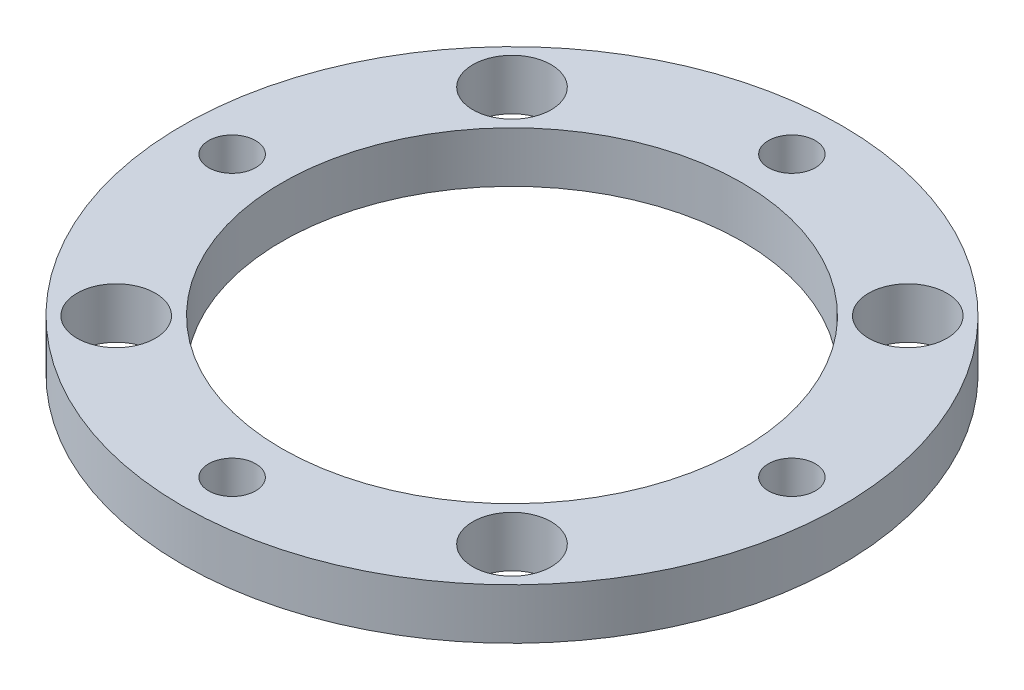
from build123d import *

# Parameters (mm, degrees)
PROFILE_SKETCH_R              = 20.6375
PROFILE_EXTRUDE_DEPTH         = 3.175
BORE_SKETCH_R                 = 14.4145
BORE_CUT_DEPTH                = 4.175
BOLT_CLEARANCE_SKETCH_R       = 1.4732
BOLT_CLEARANCE_CUT_DEPTH      = 4.175
BOLT_HEAD_CLEARANCE_SKETCH_R  = 2.4511
BOLT_HEAD_CLEARANCE_CUT_DEPTH = 4.175


with BuildPart() as part:
    # Profile Sketch → Profile Extrude (new body)
    with BuildSketch(Plane(origin=(0, 0, 0), x_dir=(1, 0, 0), z_dir=(0, 1, 0))):
        Circle(PROFILE_SKETCH_R)
    extrude(amount=PROFILE_EXTRUDE_DEPTH)

    # Bore Sketch → Bore Cut (cut, through all)
    with BuildSketch(Plane(origin=(0, 0, 0), x_dir=(-1, 0, 0), z_dir=(0, -1, 0))):
        Circle(BORE_SKETCH_R)
    extrude(amount=-BORE_CUT_DEPTH, mode=Mode.SUBTRACT)

    # Bolt Clearance Sketch → Bolt Clearance Cut (cut, through all)
    with BuildSketch(Plane.XZ):
        with Locations((0, 17.526)):
            Circle(BOLT_CLEARANCE_SKETCH_R)
        with Locations((17.526, 0)):
            Circle(BOLT_CLEARANCE_SKETCH_R)
        with Locations((0, -17.526)):
            Circle(BOLT_CLEARANCE_SKETCH_R)
        with Locations((-17.526, 0)):
            Circle(BOLT_CLEARANCE_SKETCH_R)
    extrude(amount=-BOLT_CLEARANCE_CUT_DEPTH, mode=Mode.SUBTRACT)

    # Bolt Head Clearance Sketch → Bolt Head Clearance Cut (cut, through all)
    with BuildSketch(Plane(origin=(0, 0, 0), x_dir=(-1, 0, 0), z_dir=(0, -1, 0))):
        with Locations((-12.392753447, -12.392753447)):
            Circle(BOLT_HEAD_CLEARANCE_SKETCH_R)
        with Locations((-12.392753447, 12.392753447)):
            Circle(BOLT_HEAD_CLEARANCE_SKETCH_R)
        with Locations((12.392753447, 12.392753447)):
            Circle(BOLT_HEAD_CLEARANCE_SKETCH_R)
        with Locations((12.392753447, -12.392753447)):
            Circle(BOLT_HEAD_CLEARANCE_SKETCH_R)
    extrude(amount=-BOLT_HEAD_CLEARANCE_CUT_DEPTH, mode=Mode.SUBTRACT)


solid = part.part
